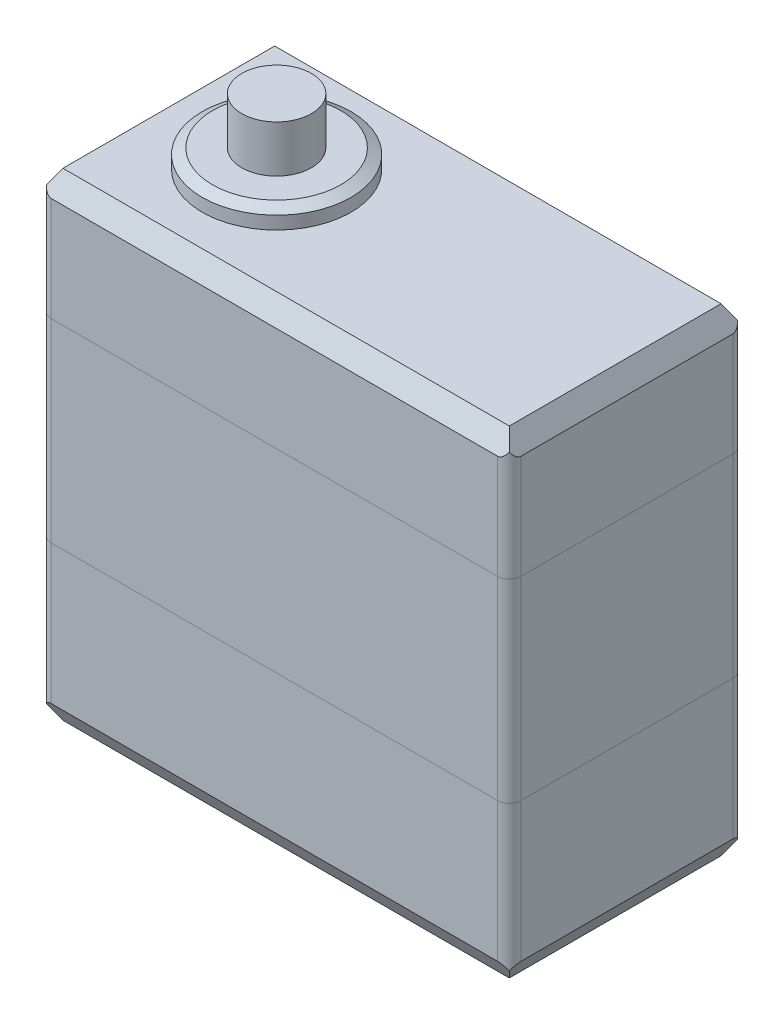
from build123d import *

# Parameters (mm, degrees)
SKETCH1_W                = 40.05
SKETCH1_H                = 20.05
BOSS_EXTRUDE1_DEPTH      = 40.75
SKETCH2_R                = 6.34
BOSS_EXTRUDE2_DEPTH      = 1.6
SKETCH3_R                = 2.97
BOSS_EXTRUDE3_DEPTH      = 4
SKETCH4_R                = 2.5
BOSS_EXTRUDE4_DEPTH      = 4
SPLIT1_SURFACE_1_1_BACK  = 69.592
SPLIT1_SURFACE_1_1_DEPTH = 139.184
SPLIT1_SURFACE_1_2_BACK  = 69.592
SPLIT1_SURFACE_1_2_DEPTH = 139.184
SPLIT1_SURFACE_2_3_BACK  = 69.592
SPLIT1_SURFACE_2_3_DEPTH = 139.184
SPLIT1_SURFACE_2_4_BACK  = 69.592
SPLIT1_SURFACE_2_4_DEPTH = 139.184
CHAMFER1_SIZE            = 1
CHAMFER1_SIZE2           = 1.732050808
CHAMFER2_SIZE            = 1
CHAMFER2_SIZE2           = 1.732050808
FILLET1_R                = 1
FILLET2_R                = 1
FILLET3_R                = 1
CHAMFER3_SIZE            = 0.5
CHAMFER3_SIZE2           = 0.866025404
CHAMFER4_SIZE            = 0.5
CHAMFER4_SIZE2           = 0.866025404
SKETCH6_W                = 6.7
SKETCH6_H                = 4
BOSS_EXTRUDE5_DEPTH      = 5.6


with BuildPart() as part:
    # Sketch1 → Boss-Extrude1 (new body)
    with BuildSketch(Plane(origin=(0, 0, 0), x_dir=(1, 0, 0), z_dir=(0, 1, 0))):
        with Locations((20.025, 10.025)):
            Rectangle(SKETCH1_W, SKETCH1_H)
    extrude(amount=BOSS_EXTRUDE1_DEPTH)

    # Sketch2 → Boss-Extrude2 (add)
    with BuildSketch(Plane(origin=(0, 40.75, 0), x_dir=(1, 0, 0), z_dir=(0, 1, 0))):
        with Locations(Location((10.19, 10.025, 0), (0, 0, 90))):
            Circle(SKETCH2_R)
    boss_extrude2 = extrude(amount=BOSS_EXTRUDE2_DEPTH)

    # Sketch3 → Boss-Extrude3 (add)
    with BuildSketch(Plane(origin=(0, 42.35, 0), x_dir=(1, 0, 0), z_dir=(0, 1, 0))):
        with Locations(Location((10.19, 10.025, 0), (0, 0, 270))):
            Circle(SKETCH3_R)
    extrude(amount=BOSS_EXTRUDE3_DEPTH)

    # Mirror1: Boss-Extrude2 across plane
    add(boss_extrude2.mirror(Plane.ZX.offset(20.375)))

    # Sketch4 → Boss-Extrude4 (add)
    with BuildSketch(Plane.XZ.offset(1.6)):
        with Locations(Location((10.19, -10.025, 0), (0, 0, 270))):
            Circle(SKETCH4_R)
    extrude(amount=BOSS_EXTRUDE4_DEPTH)


with BuildPart() as body_2:
    # Split1: the piece behind the surface
    add(part.part)
    # Split1 surface 1: a surface, the sketch's curves swept straight by 139.184 mm
    with BuildLine(Plane(origin=(40.05, 0, 0), x_dir=(0, 0, -1), z_dir=(1, 0, 0)).offset(-SPLIT1_SURFACE_1_1_BACK), mode=Mode.PRIVATE) as split1_surface_1_1_path:
        Line((0, 30.15), (20.05, 30.15))
    split1_surface_1_1 = Shell.extrude(split1_surface_1_1_path.wire(), (1 * SPLIT1_SURFACE_1_1_DEPTH, 0 * SPLIT1_SURFACE_1_1_DEPTH, 0 * SPLIT1_SURFACE_1_1_DEPTH))
    split(bisect_by=split1_surface_1_1, keep=Keep.BOTTOM)


with BuildPart() as part_1:
    add(part.part)

    # Split1: split by a surface, the side it looks to stays
    # Split1 surface 1: a surface, the sketch's curves swept straight by 139.184 mm
    with BuildLine(Plane(origin=(40.05, 0, 0), x_dir=(0, 0, -1), z_dir=(1, 0, 0)).offset(-SPLIT1_SURFACE_1_2_BACK), mode=Mode.PRIVATE) as split1_surface_1_2_path:
        Line((0, 30.15), (20.05, 30.15))
    split1_surface_1_2 = Shell.extrude(split1_surface_1_2_path.wire(), (1 * SPLIT1_SURFACE_1_2_DEPTH, 0 * SPLIT1_SURFACE_1_2_DEPTH, 0 * SPLIT1_SURFACE_1_2_DEPTH))
    split(bisect_by=split1_surface_1_2, keep=Keep.TOP)

    # Chamfer1
    chamfer1_edges = [part_1.edges().sort_by_distance(p)[0] for p in [
        (0, 40.75, -10.025),
        (20.025, 40.75, 0),
        (40.05, 40.75, -10.025),
        (20.025, 40.75, -20.05),
    ]]
    chamfer1_side = [part_1.faces().sort_by_distance(p)[0] for p in [
        (21.860232038, 40.75, -10.025),
    ]]
    chamfer(chamfer1_edges, length=CHAMFER1_SIZE, length2=CHAMFER1_SIZE2, reference=chamfer1_side[0])

    # Fillet1
    fillet1_edges = [part_1.edges().sort_by_distance(p)[0] for p in [
        (0, 34.583974596, -20.05),
        (40.05, 34.583974596, -20.05),
        (40.05, 34.583974596, 0),
        (0, 34.583974596, 0),
    ]]
    fillet(fillet1_edges, radius=FILLET1_R)

    # Chamfer3
    chamfer3_edges = [part_1.edges().sort_by_distance(p)[0] for p in [
        (10.19, 42.35, -3.685),
    ]]
    chamfer3_side = [part_1.faces().sort_by_distance(p)[0] for p in [
        (10.19, 41.55, -3.685),
    ]]
    chamfer(chamfer3_edges, length=CHAMFER3_SIZE, length2=CHAMFER3_SIZE2, reference=chamfer3_side[0])

    # Sketch6 → Boss-Extrude5 (add)
    with BuildSketch(Plane.ZY):
        with Locations((-10.025, 31.45)):
            Rectangle(SKETCH6_W, SKETCH6_H)
    extrude(amount=BOSS_EXTRUDE5_DEPTH)


with BuildPart() as body_3:
    # Split1 2 body 2: the piece behind the surface
    add(body_2.part)
    # Split1 surface 2: a surface, the sketch's curves swept straight by 139.184 mm
    with BuildLine(Plane(origin=(40.05, 0, 0), x_dir=(0, 0, -1), z_dir=(1, 0, 0)).offset(-SPLIT1_SURFACE_2_3_BACK), mode=Mode.PRIVATE) as split1_surface_2_3_path:
        Line((0, 13.6), (20.05, 13.6))
    split1_surface_2_3 = Shell.extrude(split1_surface_2_3_path.wire(), (1 * SPLIT1_SURFACE_2_3_DEPTH, 0 * SPLIT1_SURFACE_2_3_DEPTH, 0 * SPLIT1_SURFACE_2_3_DEPTH))
    split(bisect_by=split1_surface_2_3, keep=Keep.BOTTOM)

    # Chamfer2
    chamfer2_edges = [body_3.edges().sort_by_distance(p)[0] for p in [
        (20.025, 0, -20.05),
        (40.05, 0, -10.025),
        (20.025, 0, 0),
        (0, 0, -10.025),
    ]]
    chamfer2_side = [body_3.faces().sort_by_distance(p)[0] for p in [
        (21.860232038, 0, -10.025),
    ]]
    chamfer(chamfer2_edges, length=CHAMFER2_SIZE, length2=CHAMFER2_SIZE2, reference=chamfer2_side[0])

    # Fillet3
    fillet3_edges = [body_3.edges().sort_by_distance(p)[0] for p in [
        (0, 7.666025404, -20.05),
        (40.05, 7.666025404, -20.05),
        (40.05, 7.666025404, 0),
        (0, 7.666025404, 0),
    ]]
    fillet(fillet3_edges, radius=FILLET3_R)

    # Chamfer4
    chamfer4_edges = [body_3.edges().sort_by_distance(p)[0] for p in [
        (10.19, -1.6, -3.685),
    ]]
    chamfer4_side = [body_3.faces().sort_by_distance(p)[0] for p in [
        (10.19, -1.6, -3.86432228),
    ]]
    chamfer(chamfer4_edges, length=CHAMFER4_SIZE, length2=CHAMFER4_SIZE2, reference=chamfer4_side[0])


with BuildPart() as body_2_1:
    add(body_2.part)

    # Split1 2 body 2: split by a surface, the side it looks to stays
    # Split1 surface 2: a surface, the sketch's curves swept straight by 139.184 mm
    with BuildLine(Plane(origin=(40.05, 0, 0), x_dir=(0, 0, -1), z_dir=(1, 0, 0)).offset(-SPLIT1_SURFACE_2_4_BACK), mode=Mode.PRIVATE) as split1_surface_2_4_path:
        Line((0, 13.6), (20.05, 13.6))
    split1_surface_2_4 = Shell.extrude(split1_surface_2_4_path.wire(), (1 * SPLIT1_SURFACE_2_4_DEPTH, 0 * SPLIT1_SURFACE_2_4_DEPTH, 0 * SPLIT1_SURFACE_2_4_DEPTH))
    split(bisect_by=split1_surface_2_4, keep=Keep.TOP)

    # Fillet2
    fillet2_edges = [body_2_1.edges().sort_by_distance(p)[0] for p in [
        (0, 21.875, -20.05),
        (40.05, 21.875, -20.05),
        (40.05, 21.875, 0),
        (0, 21.875, 0),
    ]]
    fillet(fillet2_edges, radius=FILLET2_R)


solid = Compound([part_1.part, body_3.part, body_2_1.part])
